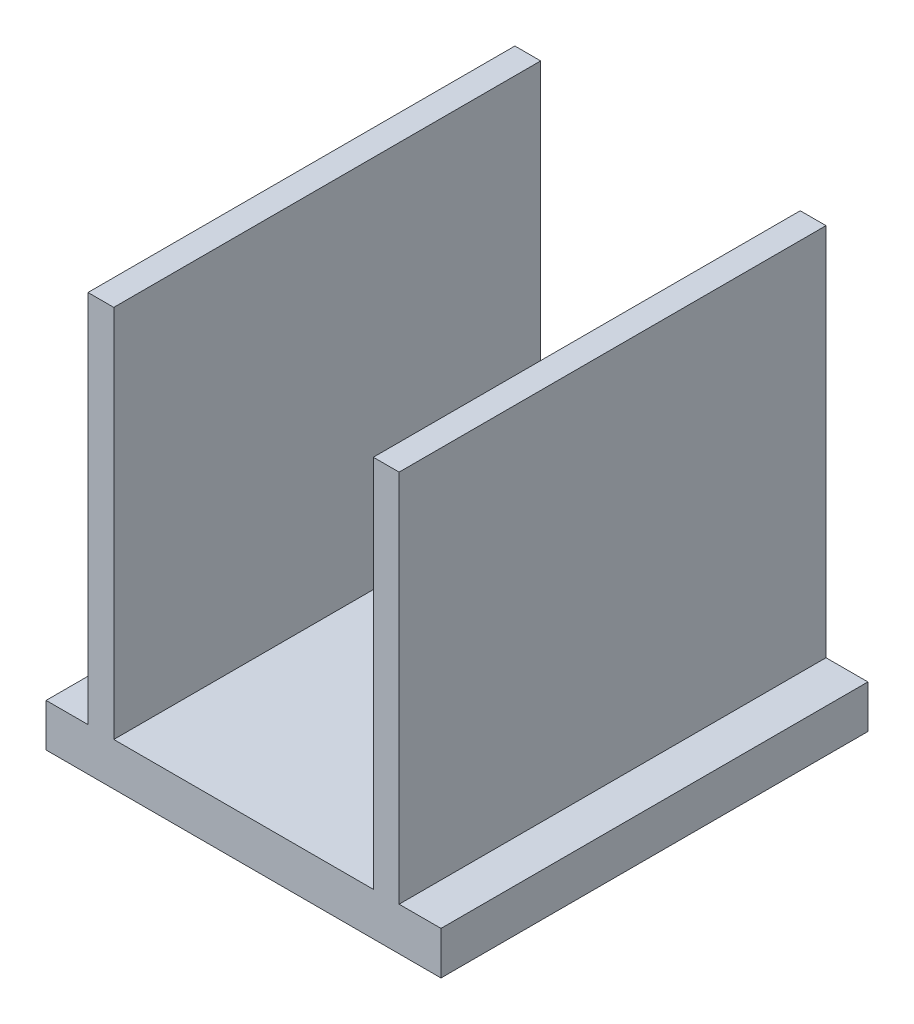
from build123d import *

# Parameters (mm, degrees)
SKETCH1_W           = 72.370080969
SKETCH1_H           = 78.237925372
BOSS_EXTRUDE1_DEPTH = 7.874
BOSS_EXTRUDE3_DEPTH = 68.58


with BuildPart() as part:
    # Sketch1 → Boss-Extrude1 (new body)
    with BuildSketch(Plane(origin=(0, 0, 0), x_dir=(1, 0, 0), z_dir=(0, 1, 0))):
        with Locations((17.407938396, 20.928645037)):
            Rectangle(SKETCH1_W, SKETCH1_H)
    extrude(amount=BOSS_EXTRUDE1_DEPTH)

    # Sketch2 → Boss-Extrude3 (add)
    with BuildSketch(Plane(origin=(0, 7.874, 0), x_dir=(1, 0, 0), z_dir=(0, 1, 0))):
        Polygon((41.192023567, 60.047607723), (41.192023567, 20.928645037), (41.192023567, -18.190317649), (45.917338502, -18.190317649), (45.917338502, 60.047607723), align=None)
        Polygon((-6.376146777, -18.190317649), (-6.376146777, 20.928645037), (-6.376146777, 60.047607723), (-11.101461711, 60.047607723), (-11.101461711, -18.190317649), align=None)
    extrude(amount=BOSS_EXTRUDE3_DEPTH)


solid = part.part
